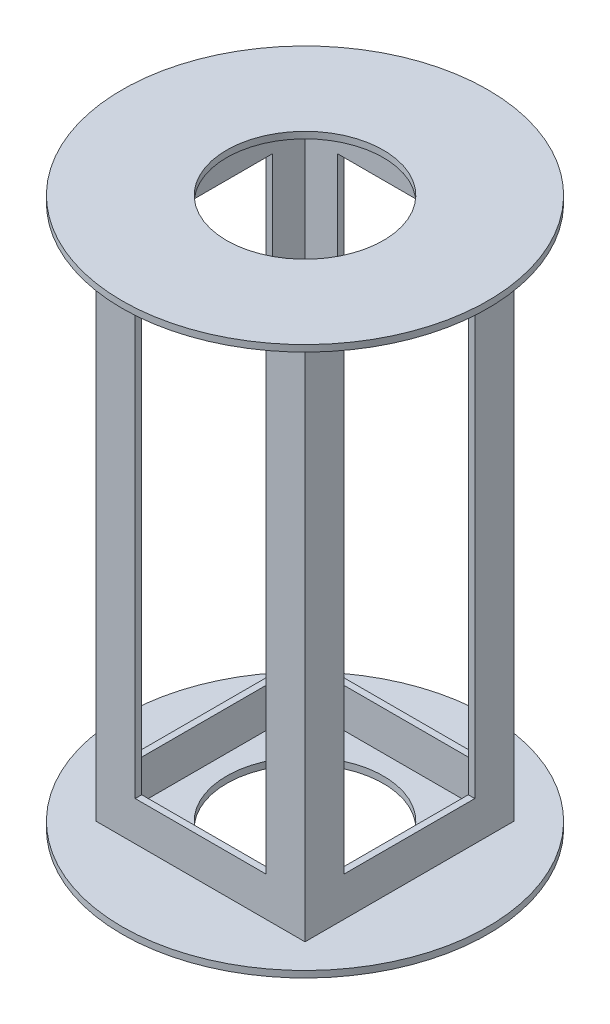
from build123d import *

# Parameters (mm, degrees)
SKETCH2_R               = 88.9
SKETCH2_R_2             = 38.1
BOSS_EXTRUDE1_DEPTH     = 3.175
SKETCH2_4_W             = 101.6
SKETCH2_4_H             = 101.6
SKETCH2_4_W_2           = 95.25
SKETCH2_4_H_2           = 95.25
BOSS_EXTRUDE2_DEPTH     = 266.7
BOSS_EXTRUDE3_START     = -3.175
SKETCH3_R               = 88.9
SKETCH3_R_2             = 38.1
BOSS_EXTRUDE3_DEPTH     = 3.175
CUT_EXTRUDE1_DEPTH      = 295.847943863
CUT_EXTRUDE1_DEPTH_BACK = 295.847943863
SKETCH4_W               = 63.5
SKETCH4_H               = 222.25
CUT_EXTRUDE2_DEPTH      = 295.847943863
CUT_EXTRUDE2_DEPTH_BACK = 295.847943863
SKETCH5_W               = 63.5
SKETCH5_H               = 222.25


with BuildPart() as part:
    # Sketch2 → Boss-Extrude1 (new body)
    with BuildSketch(Plane(origin=(0, 0, 0), x_dir=(1, 0, 0), z_dir=(0, 1, 0))):
        Circle(SKETCH2_R)
        Circle(SKETCH2_R_2, mode=Mode.SUBTRACT)
    extrude(amount=BOSS_EXTRUDE1_DEPTH)

    # Sketch2_4 → Boss-Extrude2 (add)
    with BuildSketch(Plane(origin=(0, 0, 0), x_dir=(1, 0, 0), z_dir=(0, 1, 0))):
        Rectangle(SKETCH2_4_W, SKETCH2_4_H)
        Rectangle(SKETCH2_4_W_2, SKETCH2_4_H_2, mode=Mode.SUBTRACT)
    extrude(amount=BOSS_EXTRUDE2_DEPTH)

    # Sketch3 → Boss-Extrude3 (add)
    with BuildSketch(Plane(origin=(0, 266.7, 0), x_dir=(1, 0, 0), z_dir=(0, 1, 0)).offset(BOSS_EXTRUDE3_START)):
        Circle(SKETCH3_R)
        Circle(SKETCH3_R_2, mode=Mode.SUBTRACT)
    extrude(amount=BOSS_EXTRUDE3_DEPTH)

    # Sketch4 → Cut-Extrude1 (cut, two sides: drawn at the far end of the back side and taken through both)
    with BuildSketch(Plane.XY.offset(-CUT_EXTRUDE1_DEPTH_BACK)):
        with Locations((0, 133.35)):
            Rectangle(SKETCH4_W, SKETCH4_H)
    extrude(amount=CUT_EXTRUDE1_DEPTH + CUT_EXTRUDE1_DEPTH_BACK, mode=Mode.SUBTRACT)

    # Sketch5 → Cut-Extrude2 (cut, two sides: drawn at the far end of the back side and taken through both)
    with BuildSketch(Plane(origin=(0, 0, 0), x_dir=(0, 0, -1), z_dir=(1, 0, 0)).offset(-CUT_EXTRUDE2_DEPTH_BACK)):
        with Locations((0, 133.35)):
            Rectangle(SKETCH5_W, SKETCH5_H)
    extrude(amount=CUT_EXTRUDE2_DEPTH + CUT_EXTRUDE2_DEPTH_BACK, mode=Mode.SUBTRACT)


solid = part.part
